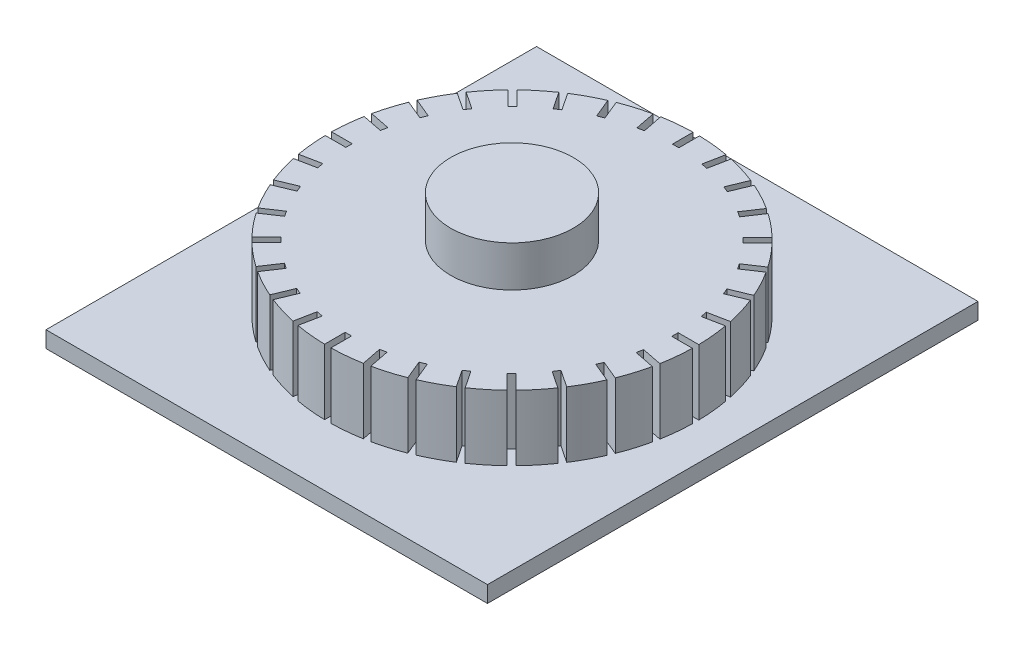
from build123d import *

# Parameters (mm, degrees)
SKETCH1_W           = 540
SKETCH1_H           = 600
BOSS_EXTRUDE1_DEPTH = 20
SKETCH2_R           = 225
BOSS_EXTRUDE2_DEPTH = 80
SKETCH3_R           = 75
BOSS_EXTRUDE3_DEPTH = 50
SKETCH4_W           = 7.808552915
SKETCH4_H           = 30.411045622
CUT_EXTRUDE2_DEPTH  = 80
CIRPATTERN1_COUNT   = 32


with BuildPart() as part:
    # Sketch1 → Boss-Extrude1 (new body)
    with BuildSketch(Plane(origin=(0, 0, 0), x_dir=(1, 0, 0), z_dir=(0, 1, 0))):
        Rectangle(SKETCH1_W, SKETCH1_H)
    extrude(amount=BOSS_EXTRUDE1_DEPTH)

    # Sketch2 → Boss-Extrude2 (add)
    with BuildSketch(Plane(origin=(0, 20, 0), x_dir=(1, 0, 0), z_dir=(0, 1, 0))):
        Circle(SKETCH2_R)
    extrude(amount=BOSS_EXTRUDE2_DEPTH)

    # Sketch3 → Boss-Extrude3 (add)
    with BuildSketch(Plane(origin=(0, 100, 0), x_dir=(1, 0, 0), z_dir=(0, 1, 0))):
        Circle(SKETCH3_R)
    extrude(amount=BOSS_EXTRUDE3_DEPTH)

    # Sketch4 → Cut-Extrude2 (cut)
    with BuildSketch(Plane(origin=(0, 100, 0), x_dir=(1, 0, 0), z_dir=(0, 1, 0))):
        with Locations((-0.422697027, -214.97303666)):
            Rectangle(SKETCH4_W, SKETCH4_H)
    cut_extrude2 = extrude(amount=-CUT_EXTRUDE2_DEPTH, mode=Mode.SUBTRACT)

    # CirPattern1: Cut-Extrude2 ×32 about axis
    cirpattern1_axis = Axis((0, 0, 0), (0, 1, 0))
    for i in range(1, CIRPATTERN1_COUNT):
        add(cut_extrude2.rotate(cirpattern1_axis, i * 360 / CIRPATTERN1_COUNT), mode=Mode.SUBTRACT)


solid = part.part
